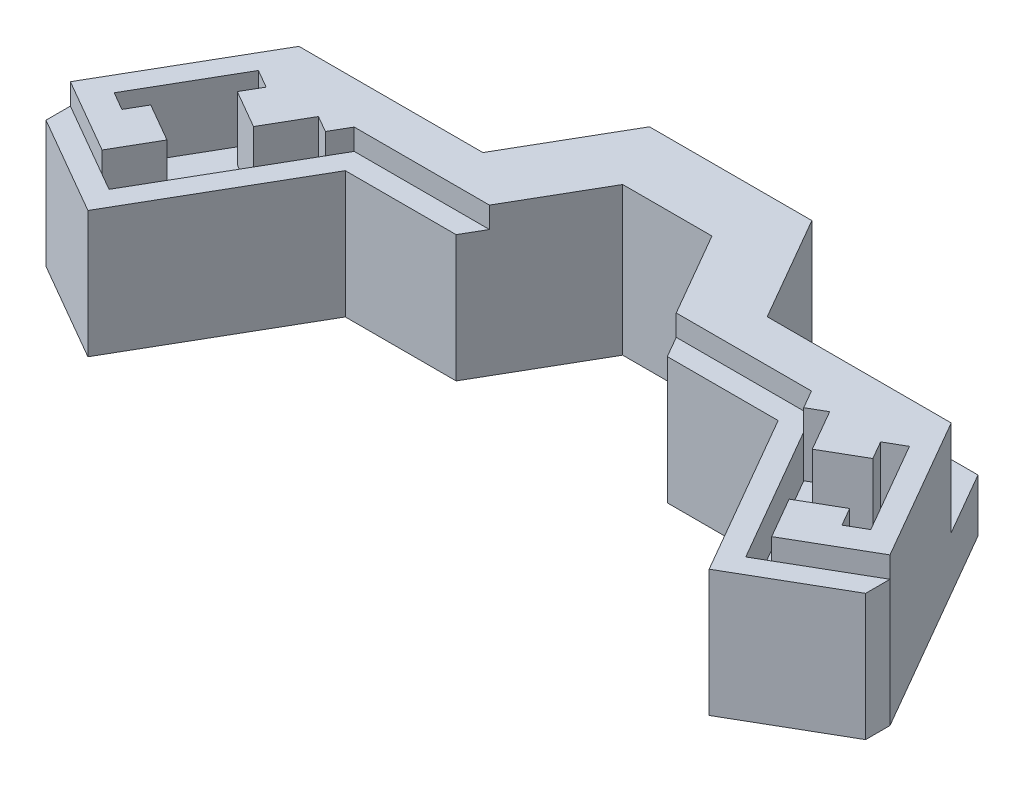
from build123d import *

# Parameters (mm, degrees)
BOSS_EXTRUDE1_DEPTH = 14
BOSS_EXTRUDE2_DEPTH = 12
CUT_EXTRUDE2_DEPTH  = 6
SKETCH7_W           = 39.032004281
SKETCH7_H           = 8.14809517
CUT_EXTRUDE3_DEPTH  = 9
CUT_EXTRUDE4_DEPTH  = 14
BOSS_EXTRUDE3_DEPTH = 14


with BuildPart() as part:
    # Sketch2 → Boss-Extrude1 (new body)
    with BuildSketch(Plane(origin=(0, 0, 0), x_dir=(1, 0, 0), z_dir=(0, 1, 0))):
        Polygon((-21.65, 0), (0, 0), (0, 10), (-27.423502692, 10), (-38.810254038, -9.722431864), (-30.15, -14.722431864), align=None)
    boss_extrude1 = extrude(amount=BOSS_EXTRUDE1_DEPTH)

    # Sketch5 → Boss-Extrude2 (add)
    with BuildSketch(Plane(origin=(0, 0, 0), x_dir=(1, 0, 0), z_dir=(0, 1, 0))):
        Polygon((-38.810254038, -9.722431864), (-38.810254038, -12.031832941), (-29.417949192, -17.454482672), (-20.495299462, -2), (0, -2), (0, 0), (-21.65, 0), (-30.15, -14.722431864), align=None)
    boss_extrude2 = extrude(amount=BOSS_EXTRUDE2_DEPTH)

    # Sketch6 → Cut-Extrude2 (cut)
    with BuildSketch(Plane(origin=(0, 14, 0), x_dir=(1, 0, 0), z_dir=(0, 1, 0))):
        Polygon((-30.15, -14.722431864), (-31.708845727, -13.822431864), (-29.458845727, -9.925317547), (-33.096152423, -7.825317547), (-34.096152423, -9.557368355), (-35.82820323, -8.557368355), (-30.82820323, 0.102885683), (-29.096152423, -0.897114317), (-30.096152423, -2.629165125), (-26.458845727, -4.729165125), (-24.208845727, -0.832050808), (-22.65, -1.732050808), align=None)
    cut_extrude2 = extrude(amount=-CUT_EXTRUDE2_DEPTH, mode=Mode.SUBTRACT)

    # Sketch7 → Cut-Extrude3 (cut)
    with BuildSketch(Plane(origin=(0, 14, 0), x_dir=(1, 0, 0), z_dir=(0, 1, 0))):
        with Locations((-15.834859511, 8.074047585)):
            Rectangle(SKETCH7_W, SKETCH7_H)
    cut_extrude3 = extrude(amount=-CUT_EXTRUDE3_DEPTH, mode=Mode.SUBTRACT)

    # Mirror2: Boss-Extrude1, Boss-Extrude2, Cut-Extrude2, Cut-Extrude3 across plane
    add(boss_extrude1.mirror(Plane(origin=(0, 0, 0), x_dir=(0, 0, 1), z_dir=(1, 0, 0))))
    add(boss_extrude2.mirror(Plane(origin=(0, 0, 0), x_dir=(0, 0, 1), z_dir=(1, 0, 0))))
    add(cut_extrude2.mirror(Plane(origin=(0, 0, 0), x_dir=(0, 0, 1), z_dir=(1, 0, 0))), mode=Mode.SUBTRACT)
    add(cut_extrude3.mirror(Plane(origin=(0, 0, 0), x_dir=(0, 0, 1), z_dir=(1, 0, 0))), mode=Mode.SUBTRACT)

    # Sketch8 → Cut-Extrude4 (cut)
    with BuildSketch(Plane(origin=(0, 14, 0), x_dir=(1, 0, 0), z_dir=(0, 1, 0))):
        Polygon((-10, -2), (-4.226497308, 8), (4.226497308, 8), (10, -2), align=None)
    extrude(amount=-CUT_EXTRUDE4_DEPTH, mode=Mode.SUBTRACT)

    # Sketch9 → Boss-Extrude3 (add)
    with BuildSketch(Plane(origin=(0, 14, 0), x_dir=(1, 0, 0), z_dir=(0, 1, 0))):
        Polygon((-13.464101615, 4), (-7.690598923, 14), (7.690598923, 14), (13.464101615, 4), (6.535898385, 4), (4.226497308, 8), (-4.226497308, 8), (-6.535898385, 4), align=None)
    extrude(amount=-BOSS_EXTRUDE3_DEPTH)


solid = part.part
